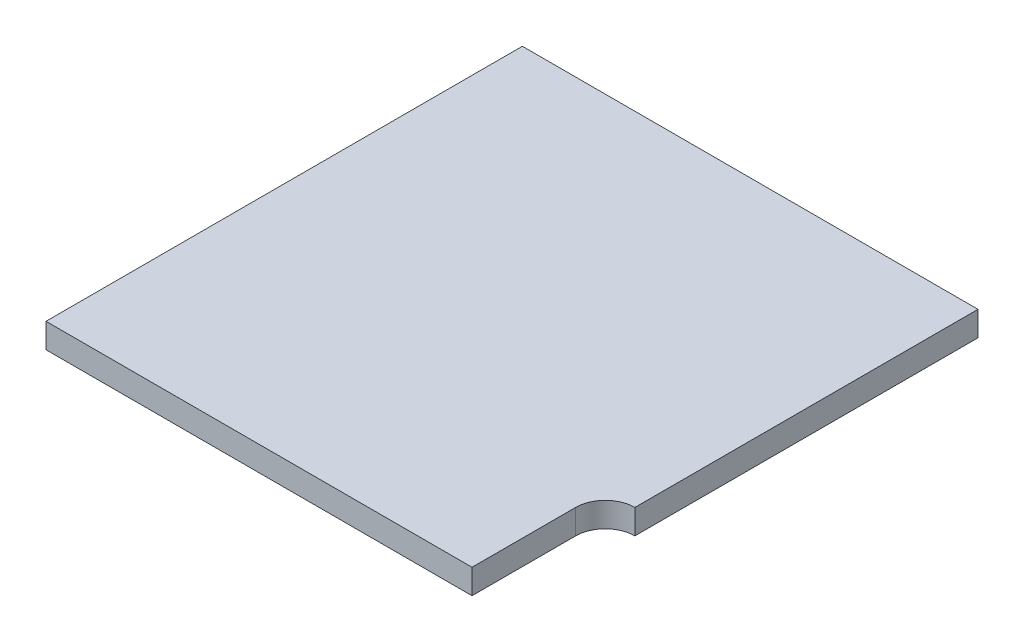
from build123d import *

# Parameters (mm, degrees)
SKETCH_1_W          = 18.46
SKETCH_1_H          = 19.3
EXTRUDE_1_DEPTH     = 1
CUT_EXTRUDE_1_DEPTH = 2


with BuildPart() as part:
    # 草图1 → 凸台-拉伸1 (new body)
    with BuildSketch(Plane(origin=(0, 0, 0), x_dir=(1, 0, 0), z_dir=(0, 1, 0))):
        Rectangle(SKETCH_1_W, SKETCH_1_H)
    extrude(amount=EXTRUDE_1_DEPTH)

    # 草图2 → 切除-拉伸1 (cut, through all)
    with BuildSketch(Plane(origin=(0, 1, 0), x_dir=(1, 0, 0), z_dir=(0, 1, 0))):
        with BuildLine():
            Line((9.23, -9.65), (8.03, -9.65))
            Line((8.03, -9.65), (8.03, -5.45))
            ThreePointArc((8.03, -5.45), (8.381471863, -4.601471863), (9.23, -4.25))
            Line((9.23, -4.25), (9.23, -9.65))
        make_face()
    extrude(amount=-CUT_EXTRUDE_1_DEPTH, mode=Mode.SUBTRACT)


solid = part.part
